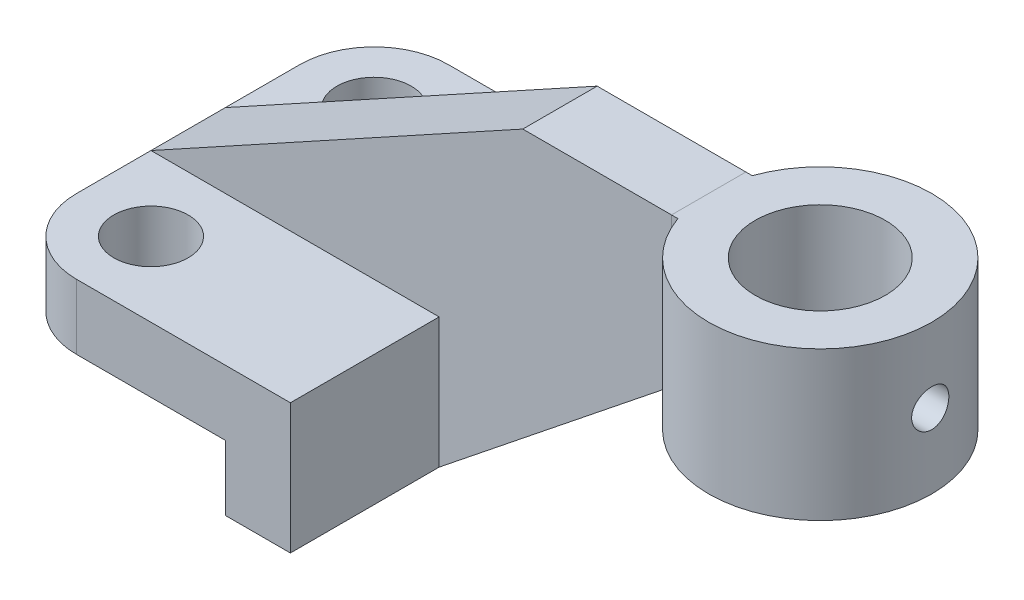
from build123d import *

# Parameters (mm, degrees)
CROQUIS1_R              = 6.35
SALIENTE_EXTRUIR3_DEPTH = 11.1125
CROQUIS3_W              = 11.1125
CROQUIS3_H              = 63.5
SALIENTE_EXTRUIR4_DEPTH = 11.1125
SALIENTE_EXTRUIR5_DEPTH = 6.35
CROQUIS6_R              = 11.1125
SALIENTE_EXTRUIR6_DEPTH = 25.4
CROQUIS7_R              = 3.175
CORTAR_EXTRUIR2_DEPTH   = 19.05


with BuildPart() as part:
    # Croquis1 → Saliente-Extruir3 (new body)
    with BuildSketch(Plane(origin=(0, 0, 0), x_dir=(1, 0, 0), z_dir=(0, 1, 0))):
        with BuildLine():
            Line((-63.5, 19.05), (-63.5, -19.05))
            ThreePointArc((-63.5, -19.05), (-59.780256121, -28.030256121), (-50.8, -31.75))
            Line((-50.8, -31.75), (-14.2875, -31.75))
            Line((-14.2875, -31.75), (-14.2875, 31.75))
            Line((-14.2875, 31.75), (-50.8, 31.75))
            ThreePointArc((-50.8, 31.75), (-59.780256121, 28.030256121), (-63.5, 19.05))
        make_face()
        with Locations((-50.8, -19.05)):
            Circle(CROQUIS1_R, mode=Mode.SUBTRACT)
        with Locations((-50.8, 19.05)):
            Circle(CROQUIS1_R, mode=Mode.SUBTRACT)
    extrude(amount=-SALIENTE_EXTRUIR3_DEPTH)

    # Croquis3 → Saliente-Extruir4 (add)
    with BuildSketch(Plane.XZ.offset(11.1125)):
        with Locations((-19.84375, 0)):
            Rectangle(CROQUIS3_W, CROQUIS3_H)
    extrude(amount=SALIENTE_EXTRUIR4_DEPTH)

    # Croquis4 → Saliente-Extruir5 (add, symmetric)
    with BuildSketch(Plane.XY):
        Polygon((-63.5, 0), (-14.2875, 0), (-14.2875, -22.225), (25.4, 9.525), (25.4, 34.925), (0, 34.925), align=None)
    extrude(amount=SALIENTE_EXTRUIR5_DEPTH, both=True)


with BuildPart() as body_2:
    # Croquis6 → Saliente-Extruir6 (new body)
    with BuildSketch(Plane(origin=(0, 34.925, 0), x_dir=(1, 0, 0), z_dir=(0, 1, 0))):
        with BuildLine():
            Line((25.4, 6.35), (26.489487758, 6.35))
            ThreePointArc((26.489487758, 6.35), (63.5, 0), (26.489487758, -6.35))
            Line((26.489487758, -6.35), (25.4, -6.35))
            Line((25.4, -6.35), (25.4, 6.35))
        make_face()
        with Locations((44.45, 0)):
            Circle(CROQUIS6_R, mode=Mode.SUBTRACT)
    extrude(amount=-SALIENTE_EXTRUIR6_DEPTH)

    # Croquis7 → Cortar-Extruir2 (cut)
    with BuildSketch(Plane(origin=(63.5, 0, 0), x_dir=(0, 0, -1), z_dir=(1, 0, 0))):
        with Locations((0, 22.225)):
            Circle(CROQUIS7_R)
    extrude(amount=-CORTAR_EXTRUIR2_DEPTH, mode=Mode.SUBTRACT)


solid = Compound([part.part, body_2.part])
